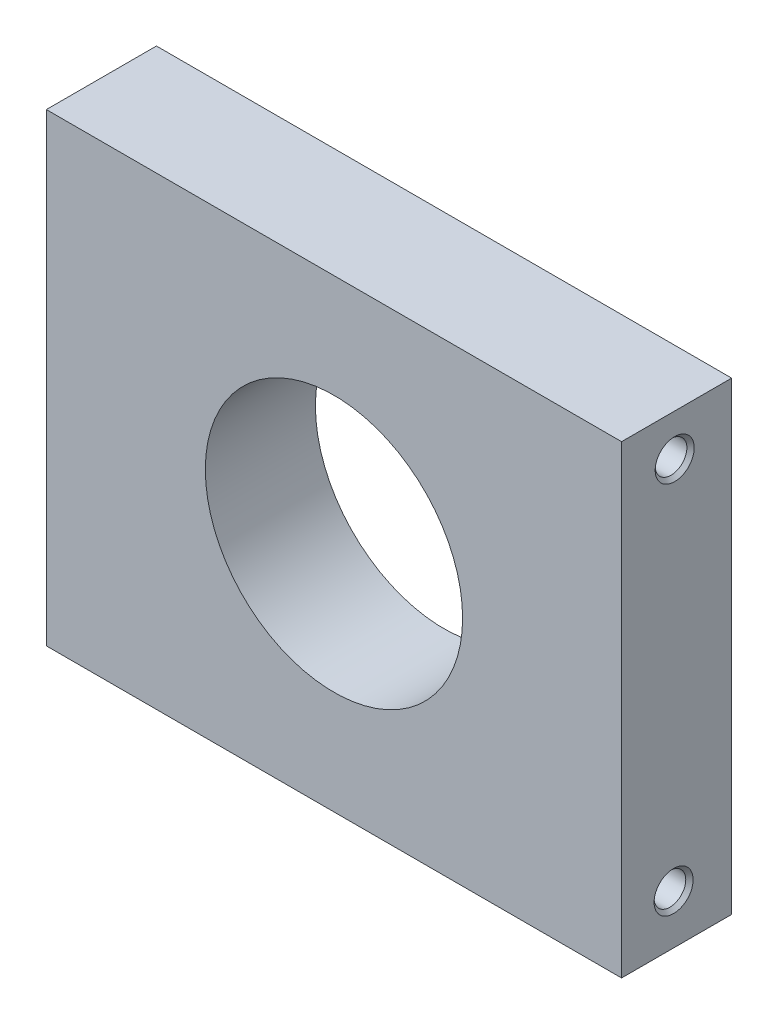
from build123d import *

# Parameters (mm, degrees)
SKETCH1_W                        = 99.549072562
SKETCH1_H                        = 80.386282086
EXTRUDE2_DEPTH                   = 19.05
SKETCH2_R                        = 22.2631
EXTRUDE3_DEPTH                   = 20.05
F_12_24_TAPPED_HOLE1_D           = 5.4864
F_12_24_TAPPED_HOLE1_CSINK_D     = 6.7564
F_12_24_TAPPED_HOLE1_CSINK_ANGLE = 90


with BuildPart() as part:
    # Sketch1 → Extrude2 (new body)
    with BuildSketch(Plane.XY):
        Rectangle(SKETCH1_W, SKETCH1_H)
    extrude(amount=EXTRUDE2_DEPTH)

    # Sketch2 → Extrude3 (cut, through all)
    with BuildSketch(Plane.XY.offset(19.05)):
        Circle(SKETCH2_R)
    extrude(amount=-EXTRUDE3_DEPTH, mode=Mode.SUBTRACT)

    # #12-24 Tapped Hole1 (through all)
    with Locations(Plane(origin=(49.774536281, 32.984966891, 9.857222688), x_dir=(0, 0, 1), z_dir=(1, 0, 0))):
        with Locations((0, 0), (0.189841536, 64.64104303)):
            CounterSinkHole(F_12_24_TAPPED_HOLE1_D / 2, F_12_24_TAPPED_HOLE1_CSINK_D / 2, counter_sink_angle=F_12_24_TAPPED_HOLE1_CSINK_ANGLE)


solid = part.part
